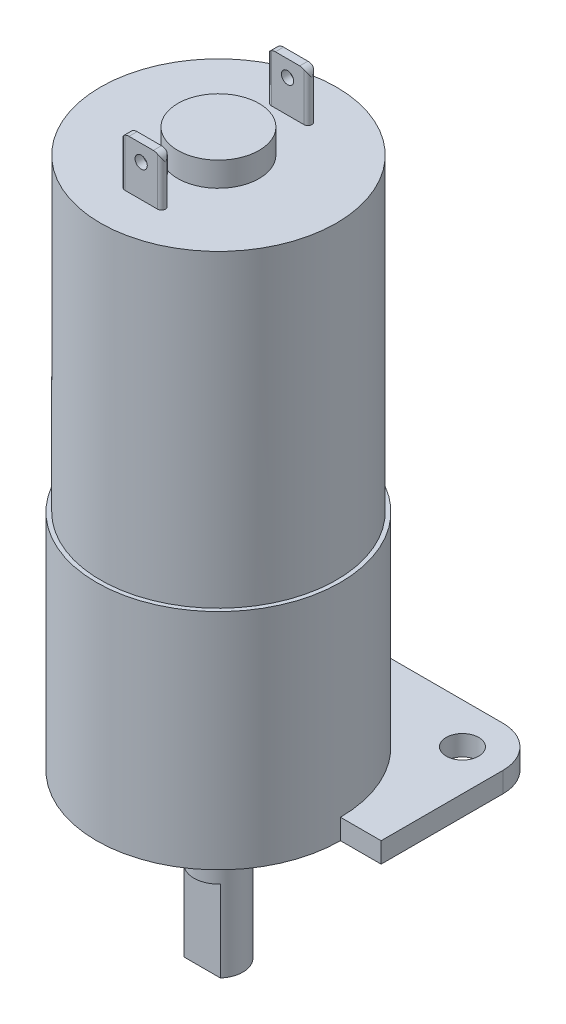
from build123d import *

# Parameters (mm, degrees)
CROQUIS1_R               = 14.5
MOTOR_DEPTH              = 38
CROQUIS2_R               = 5
SALIENTE_POSTERIOR_DEPTH = 3
BORNES_DEPTH             = 6
CROQUIS4_R               = 0.75
AGUJERO_BORNES_DEPTH     = 25
CROQUIS5_R               = 15
CAJA_REDUCTORA_DEPTH     = 25
CROQUIS6_R               = 2
BRIDA_DEPTH              = 2.5
CROQUIS7_R               = 6.5
SALIENTE_EJE_DEPTH       = 3
CROQUIS8_R               = 3
EJE_DEPTH                = 17
CORTE_PLANO_EJE_DEPTH    = 10
CROQUIS10_R              = 2
CORTE_BRIDA_DEPTH        = 10


with BuildPart() as part:
    # Croquis1 → Motor (new body)
    with BuildSketch(Plane(origin=(0, 0, 0), x_dir=(1, 0, 0), z_dir=(0, 1, 0))):
        Circle(CROQUIS1_R)
    extrude(amount=MOTOR_DEPTH)

    # Croquis2 → Saliente posterior (add)
    with BuildSketch(Plane(origin=(0, 38, 0), x_dir=(1, 0, 0), z_dir=(0, 1, 0))):
        Circle(CROQUIS2_R)
    extrude(amount=SALIENTE_POSTERIOR_DEPTH)

    # Croquis3 → Bornes (add)
    with BuildSketch(Plane(origin=(0, 38, 0), x_dir=(1, 0, 0), z_dir=(0, 1, 0))):
        with BuildLine():
            Line((-2, 9.5), (2, 9.5))
            ThreePointArc((2, 9.5), (2.5, 9), (2, 8.5))
            Line((2, 8.5), (-2, 8.5))
            ThreePointArc((-2, 8.5), (-2.5, 9), (-2, 9.5))
        make_face()
        with BuildLine():
            Line((-2, -9.5), (2, -9.5))
            ThreePointArc((2, -9.5), (2.5, -9), (2, -8.5))
            Line((2, -8.5), (-2, -8.5))
            ThreePointArc((-2, -8.5), (-2.5, -9), (-2, -9.5))
        make_face()
    extrude(amount=BORNES_DEPTH)

    # Croquis4 → Agujero Bornes (cut, through all)
    with BuildSketch(Plane.XY.offset(9.5)):
        with Locations((0, 42)):
            Circle(CROQUIS4_R)
        with BuildLine():
            ThreePointArc((2, 43.866025404), (2.366025404, 43.5), (2.5, 43))
            Line((2.5, 43), (2.5, 44))
            Line((2.5, 44), (2, 44))
            Line((2, 44), (2, 43.866025404))
        make_face()
        with BuildLine():
            ThreePointArc((1.5, 44), (1.758819045, 43.965925826), (2, 43.866025404))
            Line((2, 43.866025404), (2, 44))
            Line((2, 44), (1.5, 44))
        make_face()
        with BuildLine():
            Line((-2, 43.866025404), (-2, 44))
            Line((-2, 44), (-2.5, 44))
            Line((-2.5, 44), (-2.5, 43))
            ThreePointArc((-2.5, 43), (-2.366025404, 43.5), (-2, 43.866025404))
        make_face()
        with BuildLine():
            ThreePointArc((-2, 43.866025404), (-1.758819045, 43.965925826), (-1.5, 44))
            Line((-1.5, 44), (-2, 44))
            Line((-2, 44), (-2, 43.866025404))
        make_face()
    extrude(amount=-AGUJERO_BORNES_DEPTH, mode=Mode.SUBTRACT)

    # Croquis5 → Caja reductora (add)
    with BuildSketch(Plane.XZ):
        Circle(CROQUIS5_R)
    extrude(amount=CAJA_REDUCTORA_DEPTH)

    # Croquis6 → Brida (add)
    with BuildSketch(Plane.XZ.offset(25)):
        with BuildLine():
            Line((-15, 20), (15, 20))
            ThreePointArc((15, 20), (18.535533906, 18.535533906), (20, 15))
            Line((20, 15), (20, -15))
            ThreePointArc((20, -15), (18.535533906, -18.535533906), (15, -20))
            Line((15, -20), (-15, -20))
            ThreePointArc((-15, -20), (-18.535533906, -18.535533906), (-20, -15))
            Line((-20, -15), (-20, 15))
            ThreePointArc((-20, 15), (-18.535533906, 18.535533906), (-15, 20))
        make_face()
        with Locations((-15, 15)):
            Circle(CROQUIS6_R, mode=Mode.SUBTRACT)
        with Locations((15, 15)):
            Circle(CROQUIS6_R, mode=Mode.SUBTRACT)
        with Locations((15, -15)):
            Circle(CROQUIS6_R, mode=Mode.SUBTRACT)
        with Locations((-15, -15)):
            Circle(CROQUIS6_R, mode=Mode.SUBTRACT)
    extrude(amount=BRIDA_DEPTH)

    # Croquis7 → Saliente eje (add)
    with BuildSketch(Plane.XZ.offset(27.5)):
        Circle(CROQUIS7_R)
    extrude(amount=SALIENTE_EJE_DEPTH)

    # Croquis8 → Eje (add)
    with BuildSketch(Plane.XZ.offset(30.5)):
        Circle(CROQUIS8_R)
    extrude(amount=EJE_DEPTH)

    # Croquis9 → Corte Plano eje (cut)
    with BuildSketch(Plane.XZ.offset(47.5)):
        Polygon((-74.796206056, 2), (-2.236067977, 2), (2.236067977, 2), (74.796206056, 2), (74.796206056, 147.120276157), (-74.796206056, 147.120276157), align=None)
    extrude(amount=-CORTE_PLANO_EJE_DEPTH, mode=Mode.SUBTRACT)

    # Croquis10 → Corte Brida (cut)
    with BuildSketch(Plane(origin=(0, -25, 0), x_dir=(1, 0, 0), z_dir=(0, 1, 0))):
        with BuildLine():
            Line((20, 0), (15, 0))
            ThreePointArc((15, 0), (0, -15), (-15, 0))
            Line((-15, 0), (-20, 0))
            Line((-20, 0), (-20, -15))
            ThreePointArc((-20, -15), (-18.535533906, -18.535533906), (-15, -20))
            Line((-15, -20), (15, -20))
            ThreePointArc((15, -20), (18.535533906, -18.535533906), (20, -15))
            Line((20, -15), (20, 0))
        make_face()
        with Locations((-15, -15)):
            Circle(CROQUIS10_R, mode=Mode.SUBTRACT)
        with Locations((15, -15)):
            Circle(CROQUIS10_R, mode=Mode.SUBTRACT)
    extrude(amount=-CORTE_BRIDA_DEPTH, mode=Mode.SUBTRACT)


solid = part.part
